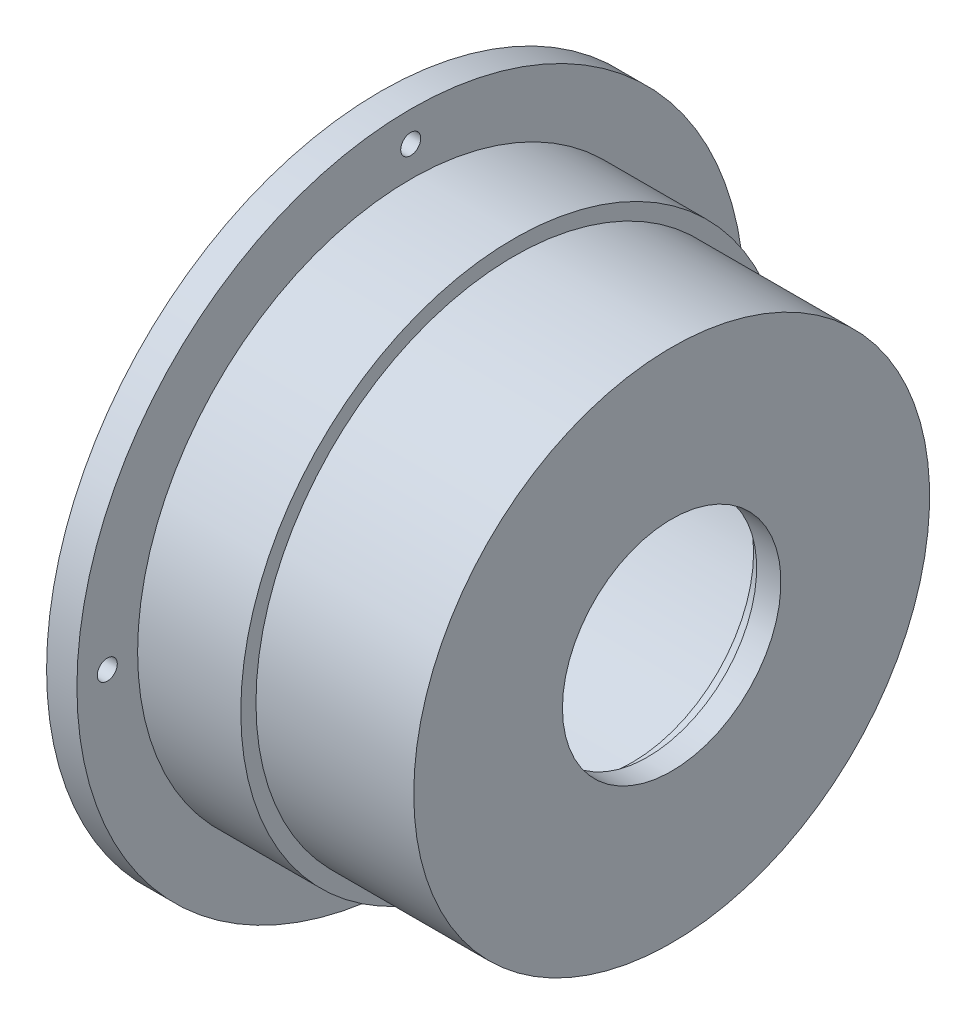
from build123d import *

# Parameters (mm, degrees)
M4X0_7_TAPPED_HOLE1_D = 3.3


with BuildPart() as part:
    # Sketch2 → Revolve1 (revolve)
    with BuildSketch(Plane.XY):
        Polygon((0, 37.6), (41.5, 37.6), (41.5, 20), (44, 20), (44, 18), (48, 18), (48, 42.5), (22, 42.5), (22, 45), (5, 45), (5, 55), (0, 55), (0, 45), align=None)
    revolve(axis=Axis((-64.103352454, 0, 0), (1, 0, 0)))

    # M4x0.7 Tapped Hole1 (through all)
    with Locations(Plane.ZY):
        with Locations((0, 50), (50, 0), (0, -50), (-50, 0)):
            Hole(M4X0_7_TAPPED_HOLE1_D / 2)


solid = part.part
